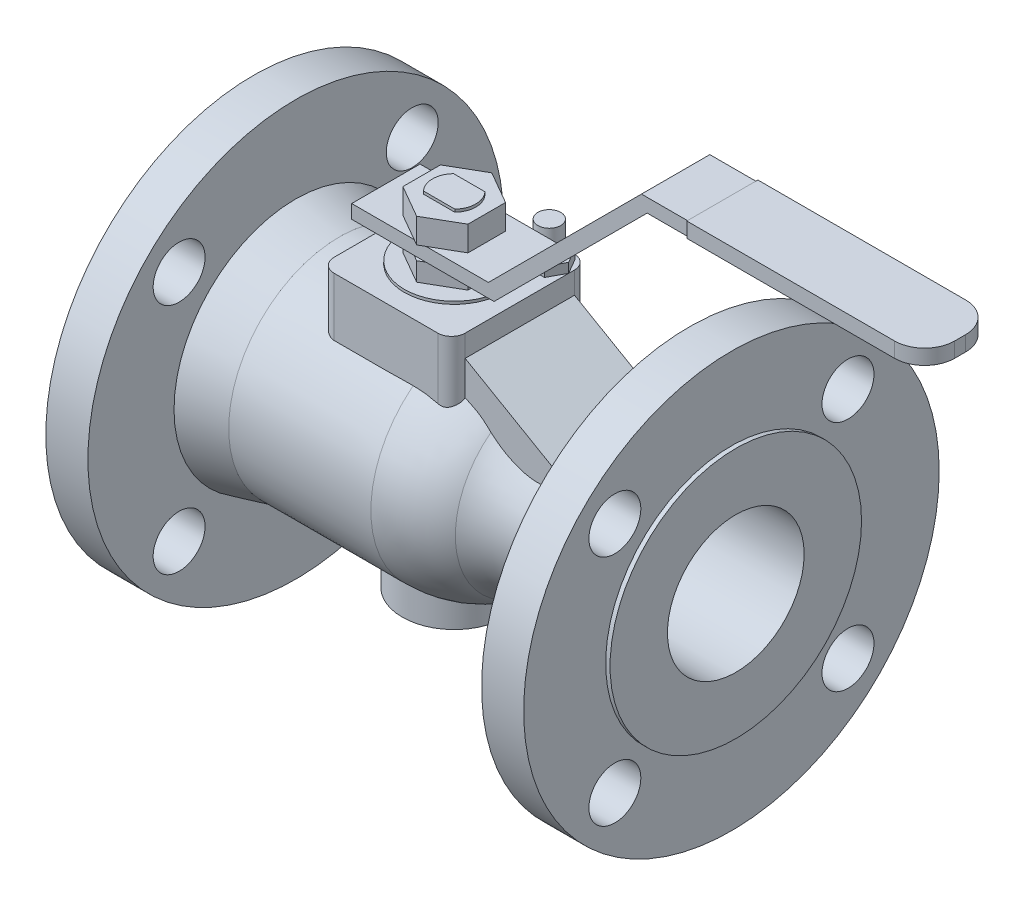
from build123d import *

# Parameters (mm, degrees)
CUT_EXTRUDE1_DEPTH        = 149.865712216
CUT_EXTRUDE1_DEPTH_BACK   = 149.865712216
SKETCH2_R                 = 9.5
SKETCH3_R                 = 19
BOSS_EXTRUDE1_DEPTH       = 49.5
BOSS_EXTRUDE2_DEPTH       = 53
BOSS_EXTRUDE3_DEPTH       = 3.5
SKETCH6_R                 = 4.181085656
BOSS_EXTRUDE4_DEPTH       = 10.5
BOSS_EXTRUDE5_DEPTH       = 20
BOSS_EXTRUDE5_DEPTH_BACK  = 20
SKETCH8_R                 = 18.25
BOSS_EXTRUDE6_DEPTH       = 1
BOSS_EXTRUDE7_DEPTH       = 20.9
BOSS_EXTRUDE8_DEPTH       = 1
BOSS_EXTRUDE9_DEPTH       = 13
BOSS_EXTRUDE9_DEPTH_BACK  = 13
SKETCH11_W                = 87
SKETCH11_H                = 5.5
BOSS_EXTRUDE10_DEPTH      = 12.5
BOSS_EXTRUDE10_DEPTH_BACK = 12.5
SKETCH13_W                = 18.25402806
SKETCH13_H                = 5
SKETCH13_W_2              = 18.513094474
CUT_EXTRUDE2_DEPTH        = 33.5
FILLET1_R                 = 11
SKETCH15_R                = 25
CUT_EXTRUDE3_DEPTH        = 298.168576422


with BuildPart() as part:
    # Sketch1 → Revolve1 (revolve)
    with BuildSketch(Plane(origin=(0, 0, 0), x_dir=(1, 0, 0), z_dir=(0, 1, 0))):
        with BuildLine():
            Line((0, 0), (-58, 0))
            Line((-58, 0), (-58, -25))
            Line((-58, -25), (-75, -25))
            Line((-75, -25), (-75, -46))
            Line((-75, -46), (-73.4, -46))
            Line((-73.4, -46), (-73.4, -76))
            Line((-73.4, -76), (-58, -76))
            Line((-58, -76), (-58, -44.5))
            Line((-58, -44.5), (-42, -40.5))
            Line((-42, -40.5), (10.000010064, -40.49998108))
            add(Edge.make_bspline(
                [(10.000010064, -40.49998108), (10.526219753, -40.510129628), (11.054794654, -40.508930399), (12.105766175, -40.484517167), (12.629410259, -40.461383486), (14.19521716, -40.361572627), (15.232308953, -40.254807969), (18.324873305, -39.823497423), (20.36220605, -39.391324106), (23.375619801, -38.490395942), (24.377508689, -38.144901813), (26.327692134, -37.36911308), (27.278680512, -36.938398435), (30.05426822, -35.508791295), (31.800819469, -34.371244158), (33.433787422, -33.031913059)],
                knots=[0, 0, 0, 0, 0.0625, 0.0625, 0.125, 0.125, 0.25, 0.25, 0.5, 0.5, 0.625, 0.625, 0.75, 0.75, 1, 1, 1, 1], degree=3))
            ThreePointArc((33.433787422, -33.031913059), (46.580609902, -27.797085655), (60.664465406, -29.170902747))
            Line((60.664465406, -29.170902747), (77.948924515, -35.194304229))
            ThreePointArc((77.948924515, -35.194304229), (83.782308782, -39.575656657), (86.000001327, -46.525941606))
            Line((86.000001327, -46.525941606), (86.000001327, -75.999996191))
            Line((86.000001327, -75.999996191), (101.400001327, -75.999996191))
            Line((101.400001327, -75.999996191), (101.400001327, -45.999996191))
            Line((101.400001327, -45.999996191), (103.000001327, -45.999996191))
            Line((103.000001327, -45.999996191), (103.000001327, -25))
            Line((103.000001327, -25), (86, -25))
            Line((86, -25), (86, 0))
            Line((86, 0), (0, 0))
        make_face()
    revolve(axis=Axis((0, 0, 0), (-1, 0, 0)))

    # Sketch2 → Cut-Extrude1 (cut, two sides: drawn at the far end of the back side and taken through both)
    with BuildSketch(Plane(origin=(0, 0, 0), x_dir=(0, 0, -1), z_dir=(1, 0, 0)).offset(-CUT_EXTRUDE1_DEPTH_BACK)):
        with Locations((-42.638538906, 42.638538906)):
            Circle(SKETCH2_R)
        with Locations((-42.638538906, -42.638538906)):
            Circle(SKETCH2_R)
        with Locations((42.638538906, 42.638538906)):
            Circle(SKETCH2_R)
        with Locations((42.638538906, -42.638538906)):
            Circle(SKETCH2_R)
    extrude(amount=CUT_EXTRUDE1_DEPTH + CUT_EXTRUDE1_DEPTH_BACK, mode=Mode.SUBTRACT)


with BuildPart() as body_2:
    # Sketch3 → Boss-Extrude1 (new body)
    with BuildSketch(Plane(origin=(0, 0, 0), x_dir=(1, 0, 0), z_dir=(0, 1, 0))):
        Circle(SKETCH3_R)
    extrude(amount=-BOSS_EXTRUDE1_DEPTH)


with BuildPart() as body_3:
    # Sketch4 → Boss-Extrude2 (new body)
    with BuildSketch(Plane(origin=(0, 0, 0), x_dir=(1, 0, 0), z_dir=(0, 1, 0))):
        with BuildLine():
            Line((19, 25), (-19, 25))
            ThreePointArc((-19, 25), (-22.535533906, 23.535533906), (-24, 20))
            Line((-24, 20), (-24, -20))
            ThreePointArc((-24, -20), (-22.535533906, -23.535533906), (-19, -25))
            Line((-19, -25), (19, -25))
            ThreePointArc((19, -25), (22.535533906, -23.535533906), (24, -20))
            Line((24, -20), (24, 20))
            ThreePointArc((24, 20), (22.535533906, 23.535533906), (19, 25))
        make_face()
    extrude(amount=BOSS_EXTRUDE2_DEPTH)


with BuildPart() as body_4:
    # Sketch5 → Boss-Extrude3 (new body)
    with BuildSketch(Plane(origin=(0, 53, 0), x_dir=(1, 0, 0), z_dir=(0, 1, 0))):
        Polygon((20.881963524, 12.12766953), (14.473375536, 12.12766953), (11.269081542, 17.67766953), (14.473375536, 23.22766953), (20.881963524, 23.22766953), (24, 17.827071933), align=None)
    extrude(amount=BOSS_EXTRUDE3_DEPTH)


with BuildPart() as body_5:
    # Sketch6 → Boss-Extrude4 (new body)
    with BuildSketch(Plane(origin=(0, 56.5, 0), x_dir=(1, 0, 0), z_dir=(0, 1, 0))):
        with Locations((17.224741608, 17.558550522)):
            Circle(SKETCH6_R)
    extrude(amount=BOSS_EXTRUDE4_DEPTH)


with BuildPart() as body_6:
    # Sketch7 → Boss-Extrude5 (new, two sides: drawn at the far end of the back side and taken through both)
    with BuildSketch(Plane.XY.offset(-BOSS_EXTRUDE5_DEPTH_BACK)):
        with BuildLine():
            Line((63.136912372, 22.404293092), (24, 45))
            Line((24, 45), (24.000144193, 32.314607945))
            add(Edge.make_bspline(
                [(24.000144193, 32.314607945), (24.864752271, 31.940638114), (25.714570904, 31.530401067), (27.370403728, 30.649393444), (28.177408944, 30.177653308), (29.750259989, 29.172690764), (30.516035688, 28.639363597), (32.006266078, 27.510985565), (32.731149586, 26.91657525), (33.433787797, 26.288935784)],
                knots=[0, 0, 0, 0, 0.25, 0.25, 0.5, 0.5, 0.75, 0.75, 1, 1, 1, 1], degree=3))
            add(Edge.make_bspline(
                [(33.433787797, 26.288935784), (34.357616868, 25.465439137), (35.315371431, 24.695832846), (37.302085075, 23.269728039), (38.330983547, 22.613133246), (40.46908469, 21.427506202), (41.579200527, 20.89788833), (43.893028873, 19.995580005), (45.067671939, 19.634621745), (47.455789254, 19.110259223), (48.669286803, 18.946973496), (50.521976993, 18.867103364), (51.146627416, 18.868278398), (52.388656063, 18.927112942), (53.009641647, 18.984785979), (54.85570469, 19.238532088), (56.054865175, 19.513017653), (58.398898581, 20.243224024), (59.543783252, 20.698905601), (60.664464078, 21.23539002)],
                knots=[0, 0, 0, 0, 0.125, 0.125, 0.25, 0.25, 0.375, 0.375, 0.5, 0.5, 0.625, 0.625, 0.6875, 0.6875, 0.75, 0.75, 0.875, 0.875, 1, 1, 1, 1], degree=3))
            add(Edge.make_bspline(
                [(60.664464078, 21.23539002), (61.48672557, 21.629017721), (62.310965482, 22.018460695), (63.136912372, 22.404293092)],
                knots=[0, 0, 0, 0, 1, 1, 1, 1], degree=3))
        make_face()
    extrude(amount=BOSS_EXTRUDE5_DEPTH + BOSS_EXTRUDE5_DEPTH_BACK)


with BuildPart() as body_7:
    # Sketch8 → Boss-Extrude6 (new body)
    with BuildSketch(Plane(origin=(0, 53, 0), x_dir=(1, 0, 0), z_dir=(0, 1, 0))):
        Circle(SKETCH8_R)
    extrude(amount=BOSS_EXTRUDE6_DEPTH)


with BuildPart() as body_8:
    # Sketch9 → Boss-Extrude7 (new body)
    with BuildSketch(Plane(origin=(0, 54, 0), x_dir=(1, 0, 0), z_dir=(0, 1, 0))):
        Polygon((-11.9, 6.870468203), (-11.9, -6.870468203), (0, -13.740936407), (11.9, -6.870468203), (11.9, 6.870468203), (0, 13.740936407), align=None)
    extrude(amount=BOSS_EXTRUDE7_DEPTH)

    # Sketch13 → Cut-Extrude2 (cut)
    with BuildSketch(Plane.ZY.offset(25)):
        with Locations((21.62701403, 63.3)):
            Rectangle(SKETCH13_W, SKETCH13_H)
        with Locations((-21.756547237, 63.3)):
            Rectangle(SKETCH13_W_2, SKETCH13_H)
    extrude(amount=-CUT_EXTRUDE2_DEPTH, mode=Mode.SUBTRACT)


with BuildPart() as body_9:
    # Sketch10 → Boss-Extrude8 (new body)
    with BuildSketch(Plane(origin=(0, 74.9, 0), x_dir=(1, 0, 0), z_dir=(0, 1, 0))):
        with BuildLine():
            Line((5.725, 5.5), (-5.725, 5.5))
            ThreePointArc((-5.725, 5.5), (-7.938867992, 0), (-5.725, -5.5))
            Line((-5.725, -5.5), (5.725, -5.5))
            ThreePointArc((5.725, -5.5), (7.938867992, 0), (5.725, 5.5))
        make_face()
    extrude(amount=BOSS_EXTRUDE8_DEPTH)


with BuildPart() as body_10:
    # Sketch11 → Boss-Extrude9 (new, two sides: drawn at the far end of the back side and taken through both)
    with BuildSketch(Plane.XY.offset(-BOSS_EXTRUDE9_DEPTH_BACK)):
        with Locations((141.571067812, 119.3)):
            Rectangle(SKETCH11_W, SKETCH11_H)
    extrude(amount=BOSS_EXTRUDE9_DEPTH + BOSS_EXTRUDE9_DEPTH_BACK)

    # Fillet1
    fillet1_edges = [body_10.edges().sort_by_distance(p)[0] for p in [
        (185.071067812, 119.3, -13),
        (185.071067812, 119.3, 13),
    ]]
    fillet(fillet1_edges, radius=FILLET1_R)


with BuildPart() as body_11:
    # Sketch12 → Boss-Extrude10 (new, two sides: drawn at the far end of the back side and taken through both)
    with BuildSketch(Plane.XY.offset(-BOSS_EXTRUDE10_DEPTH_BACK)):
        Polygon((2.149364905, 60.8), (27.071067812, 60.8), (83.071067812, 116.8), (98.071067812, 116.8), (98.071067812, 121.8), (81, 121.8), (25, 65.8), (2.149364905, 65.8), (-2.149364905, 65.8), (-25, 65.8), (-25, 60.8), (-2.149364905, 60.8), align=None)
    extrude(amount=BOSS_EXTRUDE10_DEPTH + BOSS_EXTRUDE10_DEPTH_BACK)


with BuildPart() as cut_extrude3_tool:
    # Sketch15 → Cut-Extrude3 (new, through all)
    with BuildSketch(Plane.ZY.offset(75)):
        Circle(SKETCH15_R)
    extrude(amount=-CUT_EXTRUDE3_DEPTH)


with BuildPart() as part_1:
    add(part.part)

    # Cut-Extrude3: cut by cut_extrude3_tool
    add(cut_extrude3_tool.part, mode=Mode.SUBTRACT)


with BuildPart() as body_2_1:
    add(body_2.part)

    # Cut-Extrude3: cut by cut_extrude3_tool
    add(cut_extrude3_tool.part, mode=Mode.SUBTRACT)


with BuildPart() as body_3_1:
    add(body_3.part)

    # Cut-Extrude3: cut by cut_extrude3_tool
    add(cut_extrude3_tool.part, mode=Mode.SUBTRACT)


with BuildPart() as body_6_1:
    add(body_6.part)

    # Cut-Extrude3: cut by cut_extrude3_tool
    add(cut_extrude3_tool.part, mode=Mode.SUBTRACT)


solid = Compound([body_4.part, body_5.part, body_7.part, body_8.part, body_9.part, body_10.part, body_11.part, part_1.part, body_2_1.part, body_3_1.part, body_6_1.part])
